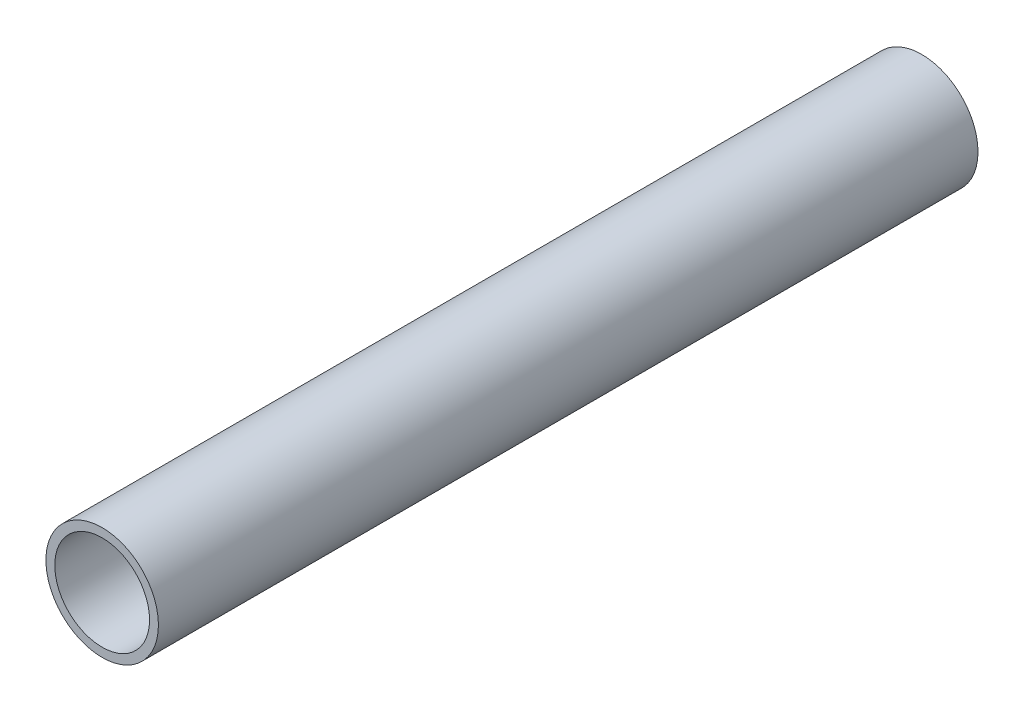
from build123d import *

# Parameters (mm, degrees)
SKETCH1_R           = 12.7
SKETCH1_R_2         = 10.7
BOSS_EXTRUDE1_DEPTH = 185


with BuildPart() as part:
    # Sketch1 → Boss-Extrude1 (new body)
    with BuildSketch(Plane.XY):
        Circle(SKETCH1_R)
        Circle(SKETCH1_R_2, mode=Mode.SUBTRACT)
    extrude(amount=BOSS_EXTRUDE1_DEPTH)


solid = part.part
